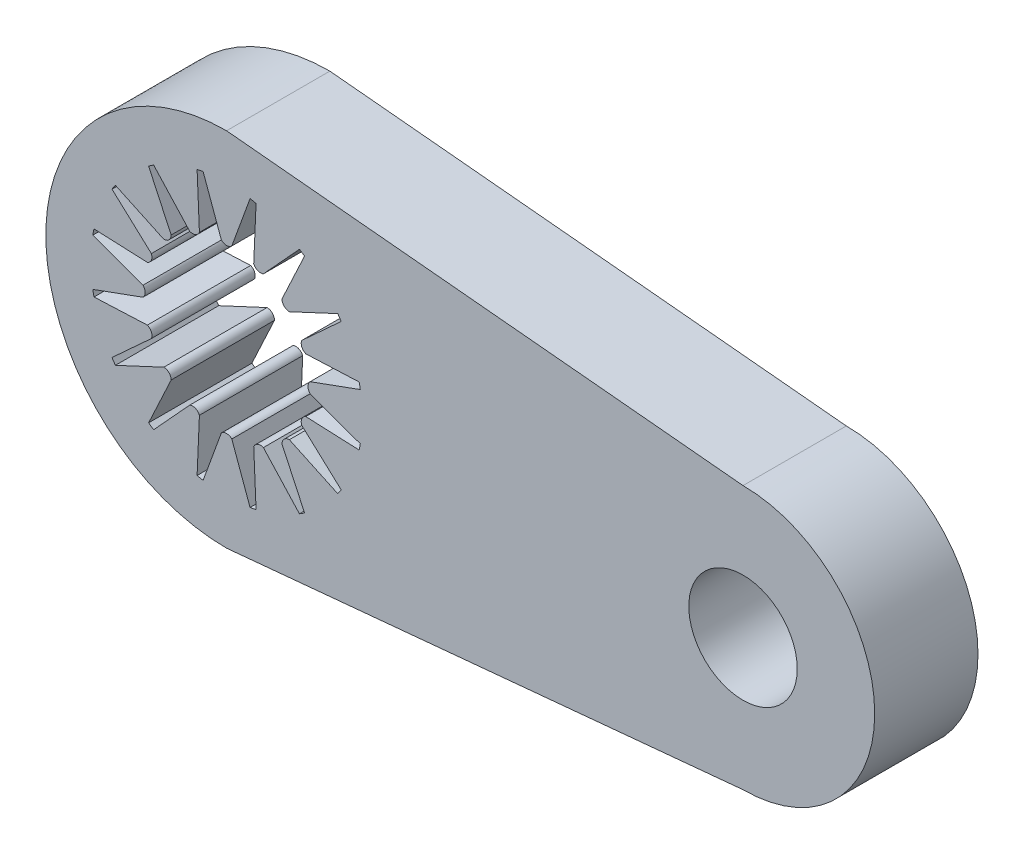
from build123d import *

# Parameters (mm, degrees)
SKETCH1_R           = 1.05
BOSS_EXTRUDE3_DEPTH = 2


with BuildPart() as part:
    # Sketch1 → Boss-Extrude3 (new body)
    with BuildSketch(Plane.XY):
        with BuildLine():
            Line((12.837896157, 8.299592267), (12.178844101, 8.362202212))
            ThreePointArc((12.178844101, 8.362202212), (8.678844101, 4.862202212), (12.178844101, 1.362202212))
            Line((12.178844101, 1.362202212), (12.837896157, 1.424812158))
            Line((12.837896157, 1.424812158), (22.178844101, 2.312202212))
            ThreePointArc((22.178844101, 2.312202212), (24.728844101, 4.862202212), (22.178844101, 7.412202212))
            Line((22.178844101, 7.412202212), (12.837896157, 8.299592267))
        make_face()
        with BuildLine():
            Line((11.619157127, 2.552399344), (11.653043843, 3.328532726))
            ThreePointArc((11.653043843, 3.328532726), (11.575639379, 3.40593719), (11.466172936, 3.40593719))
            Line((11.466172936, 3.40593719), (10.941325284, 2.833166486))
            Line((10.941325284, 2.833166486), (10.767566215, 2.643541736))
            ThreePointArc((10.767566215, 2.643541736), (10.717983865, 2.675870364), (10.669141763, 2.709306852))
            Line((10.669141763, 2.709306852), (10.777837472, 2.94240555))
            Line((10.777837472, 2.94240555), (11.106158101, 3.646491412))
            ThreePointArc((11.106158101, 3.646491412), (11.064267107, 3.747625218), (10.963133301, 3.789516212))
            Line((10.963133301, 3.789516212), (10.259047439, 3.461195582))
            Line((10.259047439, 3.461195582), (10.025948741, 3.352499874))
            ThreePointArc((10.025948741, 3.352499874), (9.992512253, 3.401341976), (9.960183625, 3.450924326))
            Line((9.960183625, 3.450924326), (10.149808375, 3.624683395))
            Line((10.149808375, 3.624683395), (10.722579079, 4.149531047))
            ThreePointArc((10.722579079, 4.149531047), (10.722579079, 4.258997489), (10.645174615, 4.336401953))
            Line((10.645174615, 4.336401953), (9.869041233, 4.302515238))
            Line((9.869041233, 4.302515238), (9.61209007, 4.291296508))
            ThreePointArc((9.61209007, 4.291296508), (9.599889846, 4.349216316), (9.588996432, 4.407396064))
            Line((9.588996432, 4.407396064), (9.830681575, 4.495362262))
            Line((9.830681575, 4.495362262), (10.560703205, 4.761068406))
            ThreePointArc((10.560703205, 4.761068406), (10.602594199, 4.862202212), (10.560703205, 4.963336018))
            Line((10.560703205, 4.963336018), (9.830681575, 5.229042162))
            Line((9.830681575, 5.229042162), (9.588996432, 5.31700836))
            ThreePointArc((9.588996432, 5.31700836), (9.599889846, 5.375188109), (9.61209007, 5.433107916))
            Line((9.61209007, 5.433107916), (9.869041233, 5.421889186))
            Line((9.869041233, 5.421889186), (10.645174615, 5.388002471))
            ThreePointArc((10.645174615, 5.388002471), (10.722579079, 5.465406935), (10.722579079, 5.574873378))
            Line((10.722579079, 5.574873378), (10.149808375, 6.099721029))
            Line((10.149808375, 6.099721029), (9.960183625, 6.273480099))
            ThreePointArc((9.960183625, 6.273480099), (9.992512253, 6.323062449), (10.025948741, 6.37190455))
            Line((10.025948741, 6.37190455), (10.259047439, 6.263208842))
            Line((10.259047439, 6.263208842), (10.963133301, 5.934888213))
            ThreePointArc((10.963133301, 5.934888213), (11.064267107, 5.976779207), (11.106158101, 6.077913013))
            Line((11.106158101, 6.077913013), (10.777837472, 6.781998874))
            Line((10.777837472, 6.781998874), (10.669141763, 7.015097573))
            ThreePointArc((10.669141763, 7.015097573), (10.717983865, 7.048534061), (10.767566215, 7.080862689))
            Line((10.767566215, 7.080862689), (10.941325284, 6.891237939))
            Line((10.941325284, 6.891237939), (11.466172936, 6.318467235))
            ThreePointArc((11.466172936, 6.318467235), (11.575639379, 6.318467235), (11.653043843, 6.395871699))
            Line((11.653043843, 6.395871699), (11.619157127, 7.172005081))
            Line((11.619157127, 7.172005081), (11.607938397, 7.428956244))
            ThreePointArc((11.607938397, 7.428956244), (11.665858205, 7.441156468), (11.724037954, 7.452049882))
            Line((11.724037954, 7.452049882), (11.812004151, 7.210364739))
            Line((11.812004151, 7.210364739), (12.077710295, 6.480343109))
            ThreePointArc((12.077710295, 6.480343109), (12.178844101, 6.438452114), (12.279977907, 6.480343109))
            Line((12.279977907, 6.480343109), (12.545684051, 7.210364739))
            Line((12.545684051, 7.210364739), (12.633650249, 7.452049882))
            ThreePointArc((12.633650249, 7.452049882), (12.691829998, 7.441156468), (12.749749805, 7.428956244))
            Line((12.749749805, 7.428956244), (12.738531075, 7.172005081))
            Line((12.738531075, 7.172005081), (12.70464436, 6.395871699))
            ThreePointArc((12.70464436, 6.395871699), (12.782048824, 6.318467235), (12.891515267, 6.318467235))
            Line((12.891515267, 6.318467235), (13.416362918, 6.891237939))
            Line((13.416362918, 6.891237939), (13.590121988, 7.080862689))
            ThreePointArc((13.590121988, 7.080862689), (13.639704338, 7.048534061), (13.688546439, 7.015097573))
            Line((13.688546439, 7.015097573), (13.579850731, 6.781998874))
            Line((13.579850731, 6.781998874), (13.251530102, 6.077913013))
            ThreePointArc((13.251530102, 6.077913013), (13.293421096, 5.976779207), (13.394554902, 5.934888213))
            Line((13.394554902, 5.934888213), (14.098640763, 6.263208842))
            Line((14.098640763, 6.263208842), (14.331739462, 6.37190455))
            ThreePointArc((14.331739462, 6.37190455), (14.36517595, 6.323062449), (14.397504578, 6.273480099))
            Line((14.397504578, 6.273480099), (14.207879828, 6.099721029))
            Line((14.207879828, 6.099721029), (13.635109124, 5.574873378))
            ThreePointArc((13.635109124, 5.574873378), (13.635109124, 5.465406935), (13.712513588, 5.388002471))
            Line((13.712513588, 5.388002471), (14.48864697, 5.421889186))
            Line((14.48864697, 5.421889186), (14.745598133, 5.433107916))
            ThreePointArc((14.745598133, 5.433107916), (14.757798357, 5.375188109), (14.768691771, 5.31700836))
            Line((14.768691771, 5.31700836), (14.527006628, 5.229042162))
            Line((14.527006628, 5.229042162), (13.796984998, 4.963336018))
            ThreePointArc((13.796984998, 4.963336018), (13.755094004, 4.862202212), (13.796984998, 4.761068406))
            Line((13.796984998, 4.761068406), (14.527006628, 4.495362262))
            Line((14.527006628, 4.495362262), (14.768691771, 4.407396064))
            ThreePointArc((14.768691771, 4.407396064), (14.757798357, 4.349216316), (14.745598133, 4.291296508))
            Line((14.745598133, 4.291296508), (14.48864697, 4.302515238))
            Line((14.48864697, 4.302515238), (13.712513588, 4.336401953))
            ThreePointArc((13.712513588, 4.336401953), (13.635109124, 4.258997489), (13.635109124, 4.149531047))
            Line((13.635109124, 4.149531047), (14.207879828, 3.624683395))
            Line((14.207879828, 3.624683395), (14.397504578, 3.450924326))
            ThreePointArc((14.397504578, 3.450924326), (14.36517595, 3.401341976), (14.331739462, 3.352499874))
            Line((14.331739462, 3.352499874), (14.098640763, 3.461195582))
            Line((14.098640763, 3.461195582), (13.394554902, 3.789516212))
            ThreePointArc((13.394554902, 3.789516212), (13.293421096, 3.747625218), (13.251530102, 3.646491412))
            Line((13.251530102, 3.646491412), (13.579850731, 2.94240555))
            Line((13.579850731, 2.94240555), (13.688546439, 2.709306852))
            ThreePointArc((13.688546439, 2.709306852), (13.639704338, 2.675870364), (13.590121988, 2.643541736))
            Line((13.590121988, 2.643541736), (13.416362918, 2.833166486))
            Line((13.416362918, 2.833166486), (12.891515267, 3.40593719))
            ThreePointArc((12.891515267, 3.40593719), (12.782048824, 3.40593719), (12.70464436, 3.328532726))
            Line((12.70464436, 3.328532726), (12.738531075, 2.552399344))
            Line((12.738531075, 2.552399344), (12.749749805, 2.295448181))
            ThreePointArc((12.749749805, 2.295448181), (12.691829998, 2.283247957), (12.633650249, 2.272354543))
            Line((12.633650249, 2.272354543), (12.545684051, 2.514039686))
            Line((12.545684051, 2.514039686), (12.279977907, 3.244061316))
            ThreePointArc((12.279977907, 3.244061316), (12.178844101, 3.28595231), (12.077710295, 3.244061316))
            Line((12.077710295, 3.244061316), (11.812004151, 2.514039686))
            Line((11.812004151, 2.514039686), (11.724037954, 2.272354543))
            ThreePointArc((11.724037954, 2.272354543), (11.665858205, 2.283247957), (11.607938397, 2.295448181))
            Line((11.607938397, 2.295448181), (11.619157127, 2.552399344))
        make_face(mode=Mode.SUBTRACT)
        with Locations((22.178844101, 4.862202212)):
            Circle(SKETCH1_R, mode=Mode.SUBTRACT)
    extrude(amount=BOSS_EXTRUDE3_DEPTH)


solid = part.part
